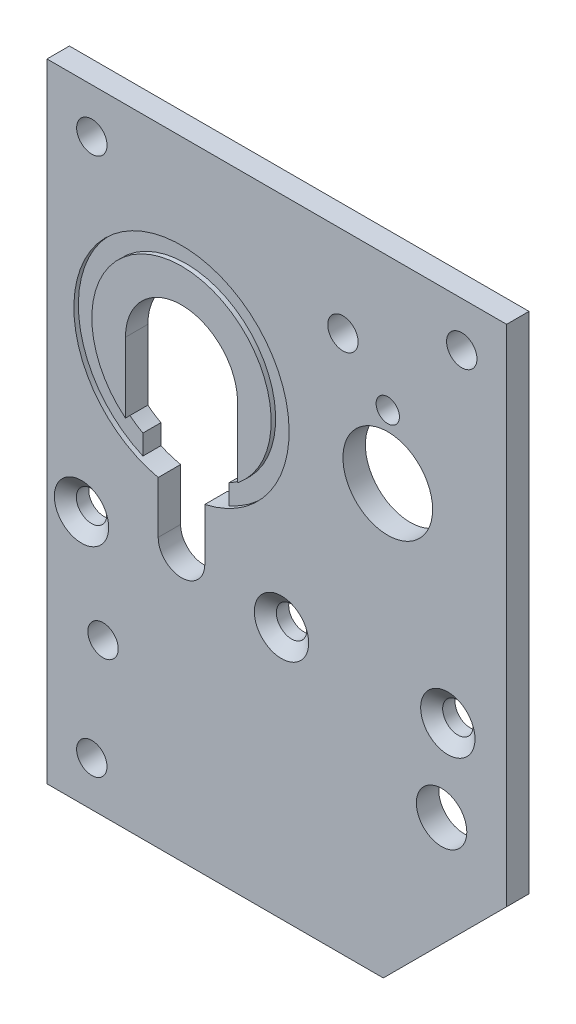
from build123d import *

# Parameters (mm, degrees)
BOSS_EXTRUDE1_DEPTH                       = 3.175
F_6_CLEARANCE_HOLE1_D                     = 4.3053
CUT_EXTRUDE1_DEPTH                        = 4.175
SKETCH5_R                                 = 6.35
SKETCH5_R_2                               = 1.651
CUT_EXTRUDE2_DEPTH                        = 4.175
F_1_4_CLEARANCE_HOLE1_D                   = 7.14248
BOSS_EXTRUDE2_DEPTH                       = 3.175
CUT_EXTRUDE3_DEPTH                        = 0.635
CSK_FOR_6_FLAT_HEAD_MACHINE_SCREW_2_COUNT = 2
CSK_FOR_6_FLAT_HEAD_MACHINE_SCREW_2_PITCH = 28.321
CSK_FOR_6_FLAT_HEAD_MACHINE_SCREW_3_COUNT = 2
CSK_FOR_6_FLAT_HEAD_MACHINE_SCREW_3_PITCH = 23.555999878


with BuildPart() as part:
    # Sketch1 → Boss-Extrude1 (new body)
    with BuildSketch(Plane.XY):
        Polygon((-65.0875, 0), (-65.0875, -88.9), (-17.4625, -88.9), (0, -71.4375), (0, 0), align=None)
    extrude(amount=-BOSS_EXTRUDE1_DEPTH)

    # #6 Clearance Hole1 (through all)
    with Locations(Plane.XY):
        with Locations((-58.7375, -6.35), (-6.35, -6.35), (-23.1775, -12.7), (-57.15, -67.31), (-58.7375, -82.55)):
            Hole(F_6_CLEARANCE_HOLE1_D / 2)

    # Sketch4 → Cut-Extrude1 (cut, through all)
    with BuildSketch(Plane.XY):
        with BuildLine():
            Line((-49.3395, -50.8), (-49.3395, -43.4529836))
            ThreePointArc((-49.3395, -43.4529836), (-46.0375, -13.335), (-42.7355, -43.4529836))
            Line((-42.7355, -43.4529836), (-42.7355, -50.8))
            ThreePointArc((-42.7355, -50.8), (-46.0375, -54.102), (-49.3395, -50.8))
        make_face()
    extrude(amount=-CUT_EXTRUDE1_DEPTH, mode=Mode.SUBTRACT)

    # Sketch5 → Cut-Extrude2 (cut, through all)
    with BuildSketch(Plane.XY):
        with Locations((-16.8275, -27.94)):
            Circle(SKETCH5_R)
        with Locations((-16.8275, -18.9484)):
            Circle(SKETCH5_R_2)
    extrude(amount=-CUT_EXTRUDE2_DEPTH, mode=Mode.SUBTRACT)

    # 1/4 Clearance Hole1 (through all)
    with Locations(Plane.XY):
        with Locations((-9.2075, -65.0875)):
            Hole(F_1_4_CLEARANCE_HOLE1_D / 2)

    # Sketch8 → Boss-Extrude2 (add, through all)
    with BuildSketch(Plane(origin=(0, 0, -3.175), x_dir=(-1, 0, 0), z_dir=(0, 0, -1))):
        with BuildLine():
            Line((52.1335, -39.716309797), (52.1335, -42.542690718))
            ThreePointArc((52.1335, -42.542690718), (46.0375, -13.335), (39.9415, -42.542690718))
            Line((39.9415, -42.542690718), (39.9415, -39.716309797))
            ThreePointArc((39.9415, -39.716309797), (38.993964439, -39.142809934), (38.1, -38.488934323))
            Line((38.1, -38.488934323), (38.1, -28.575))
            ThreePointArc((38.1, -28.575), (46.0375, -20.6375), (53.975, -28.575))
            Line((53.975, -28.575), (53.975, -38.488934323))
            ThreePointArc((53.975, -38.488934323), (53.081035561, -39.142809934), (52.1335, -39.716309797))
        make_face()
    extrude(amount=-BOSS_EXTRUDE2_DEPTH)

    # Sketch9 → Cut-Extrude3 (cut)
    with BuildSketch(Plane.XY):
        with BuildLine():
            Line((-52.1335, -39.716309797), (-52.1335, -42.542690718))
            ThreePointArc((-52.1335, -42.542690718), (-46.0375, -13.335), (-39.9415, -42.542690718))
            Line((-39.9415, -42.542690718), (-39.9415, -39.716309797))
            ThreePointArc((-39.9415, -39.716309797), (-38.993964439, -39.142809934), (-38.1, -38.488934323))
            ThreePointArc((-38.1, -38.488934323), (-46.0375, -15.875), (-53.975, -38.488934323))
            ThreePointArc((-53.975, -38.488934323), (-53.081035561, -39.142809934), (-52.1335, -39.716309797))
        make_face()
    extrude(amount=-CUT_EXTRUDE3_DEPTH, mode=Mode.SUBTRACT)

    # Sketch10 → CSK for #6 Flat Head Machine Screw (100)1 (revolve, cut)
    with BuildSketch(Plane(origin=(-31.877, -53.091877173, 0), x_dir=(0, -1, 0), z_dir=(1, 0, 0))):
        Polygon((0, 0), (0, 3.175), (2.15265, 3.175), (2.15265, 1.420893136), (3.8460045, 0), align=None)
    csk_for_6_flat_head_machine_screw_100 = revolve(axis=Axis((-31.877, -53.091877173, 6.35), (0, 0, -1)), mode=Mode.SUBTRACT)

    # CSK for _6 Flat Head Machine Screw _ 2: CSK for #6 Flat Head Machine Screw (100)1 ×2
    with Locations(*[(-i * CSK_FOR_6_FLAT_HEAD_MACHINE_SCREW_2_PITCH, 0, 0) for i in range(1, CSK_FOR_6_FLAT_HEAD_MACHINE_SCREW_2_COUNT)]):
        add(csk_for_6_flat_head_machine_screw_100, mode=Mode.SUBTRACT)

    # CSK for _6 Flat Head Machine Screw _ 3: CSK for #6 Flat Head Machine Screw (100)1 ×2
    with Locations(*[(i * CSK_FOR_6_FLAT_HEAD_MACHINE_SCREW_3_PITCH, 0, 0) for i in range(1, CSK_FOR_6_FLAT_HEAD_MACHINE_SCREW_3_COUNT)]):
        add(csk_for_6_flat_head_machine_screw_100, mode=Mode.SUBTRACT)


solid = part.part
